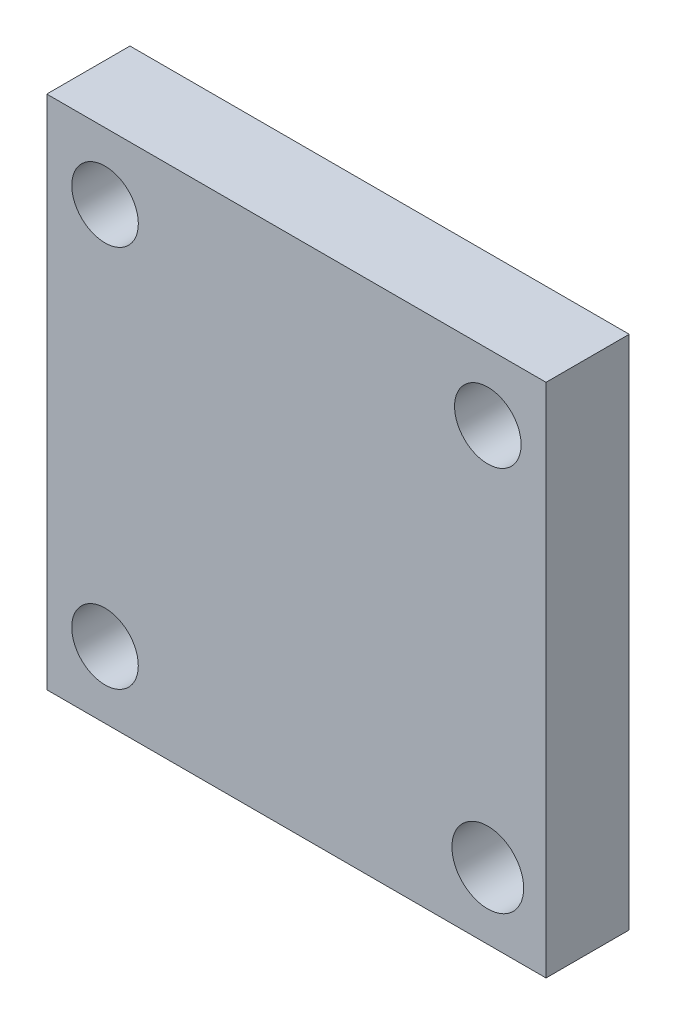
from build123d import *

# Parameters (mm, degrees)
SKETCH2_W           = 30.002183488
SKETCH2_H           = 31.002183488
SKETCH2_R           = 2
SKETCH2_R_2         = 2.156266898
BOSS_EXTRUDE1_DEPTH = 5


with BuildPart() as part:
    # Sketch2 → Boss-Extrude1 (new body)
    with BuildSketch(Plane.XY):
        Rectangle(SKETCH2_W, SKETCH2_H)
        with Locations((-11.498908256, 11.503275233)):
            Circle(SKETCH2_R, mode=Mode.SUBTRACT)
        with Locations((11.503275233, 11.501091744)):
            Circle(SKETCH2_R, mode=Mode.SUBTRACT)
        with Locations((-11.501091744, -11.498908256)):
            Circle(SKETCH2_R, mode=Mode.SUBTRACT)
        with Locations((11.501091744, -11.501091744)):
            Circle(SKETCH2_R_2, mode=Mode.SUBTRACT)
    extrude(amount=BOSS_EXTRUDE1_DEPTH)


solid = part.part
